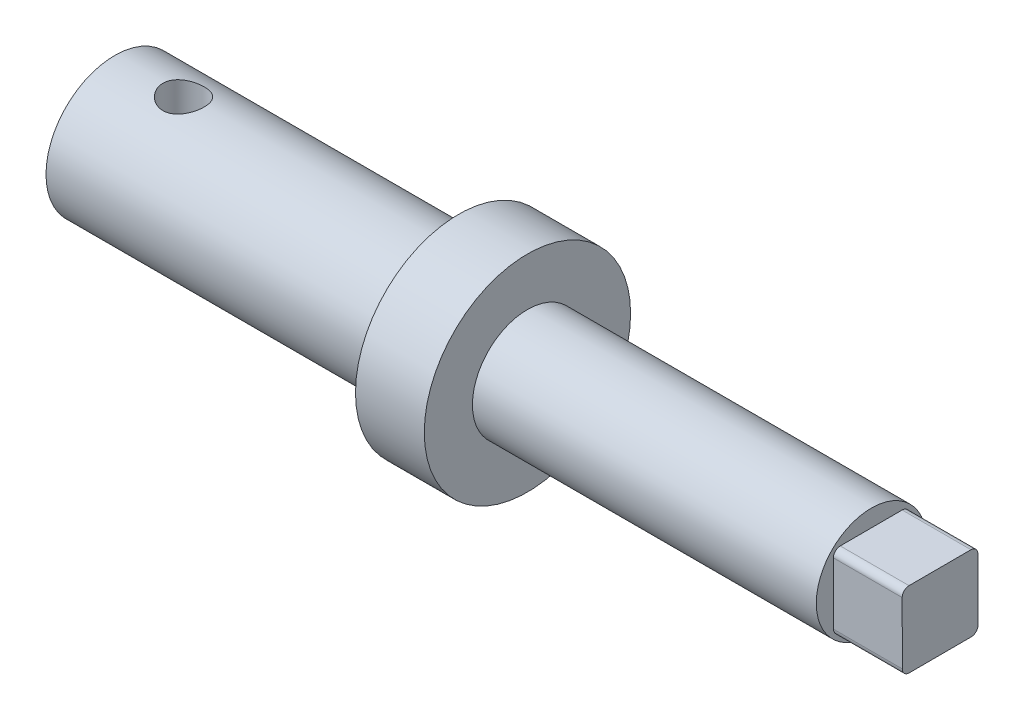
from build123d import *

# Parameters (mm, degrees)
SKETCH_2_R          = 1.5
CUT_EXTRUDE_1_DEPTH = 5
EXTRUDE_1_DEPTH     = 5
FILLET_1_R          = 0.5


with BuildPart() as part:
    # 草图1 → 旋转1 (revolve)
    with BuildSketch(Plane.XY):
        Polygon((0, 0), (0, 5), (25, 5), (25, 7.5), (30, 7.5), (30, 4), (55, 4), (55, 0), align=None)
    revolve(axis=Axis((0, 0, 0), (1, 0, 0)))

    # 草图2 → 切除-拉伸1 (cut, symmetric)
    with BuildSketch(Plane(origin=(0, 0, 0), x_dir=(1, 0, 0), z_dir=(0, 1, 0))):
        with Locations((5, 0)):
            Circle(SKETCH_2_R)
    extrude(amount=CUT_EXTRUDE_1_DEPTH, both=True, mode=Mode.SUBTRACT)

    # 草图3 → 凸台-拉伸1 (add)
    with BuildSketch(Plane(origin=(55, 0, 0), x_dir=(0, 0, -1), z_dir=(1, 0, 0))):
        Polygon((-2.757308573, 2.742691427), (-2.742691427, -2.757308573), (2.757308573, -2.742691427), (2.742691427, 2.757308573), align=None)
    extrude(amount=EXTRUDE_1_DEPTH)

    # 圆角1
    fillet_1_edges = [part.edges().sort_by_distance(p)[0] for p in [
        (57.5, 2.757308573, -2.742691427),
        (57.5, 2.742691427, 2.757308573),
        (57.5, -2.757308573, 2.742691427),
        (57.5, -2.742691427, -2.757308573),
    ]]
    fillet(fillet_1_edges, radius=FILLET_1_R)


solid = part.part
